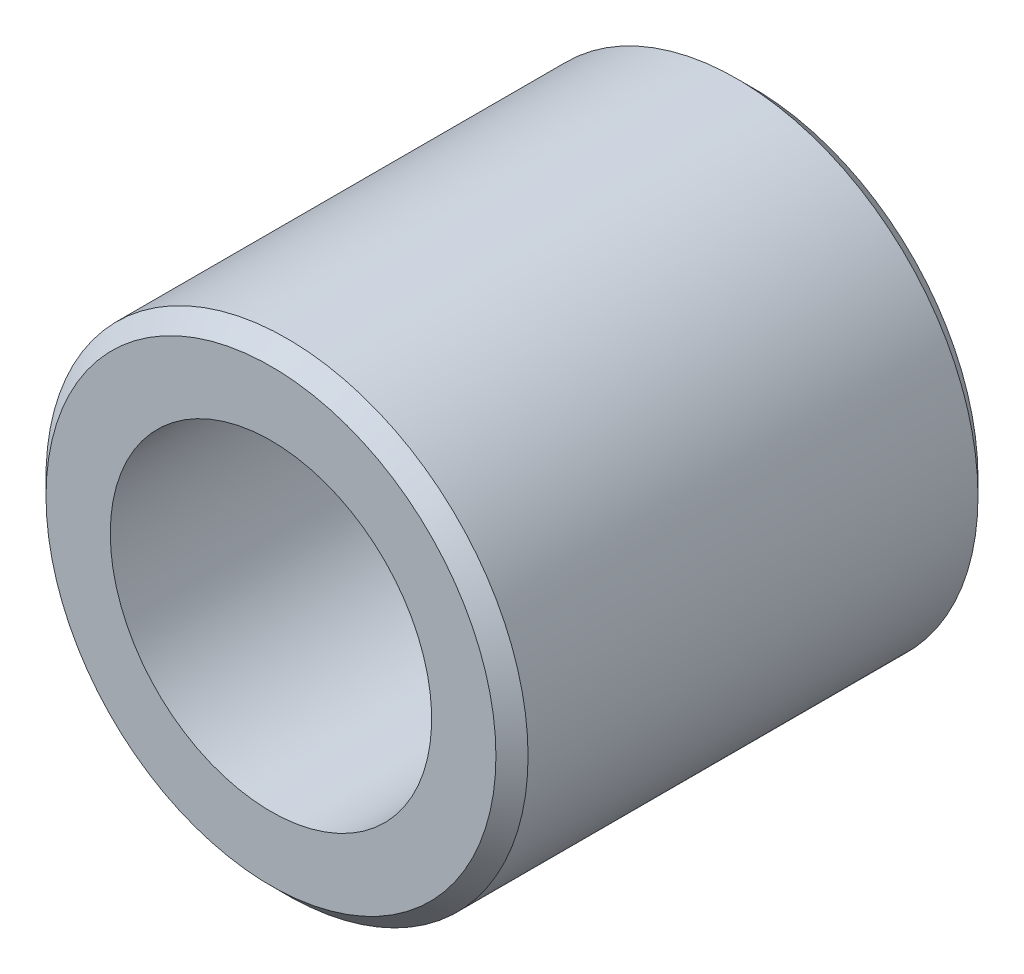
from build123d import *

# Parameters (mm, degrees)
IZIM1_R                     = 15
Y_KSEKLIK_EKSTR_ZYON1_DEPTH = 30
IZIM2_R                     = 10
KES_EKSTR_ZYON1_DEPTH       = 31
PAH1_SIZE                   = 1


with BuildPart() as part:
    # Çizim1 → Yükseklik-Ekstrüzyon1 (new body)
    with BuildSketch(Plane.XY):
        Circle(IZIM1_R)
    extrude(amount=Y_KSEKLIK_EKSTR_ZYON1_DEPTH)

    # Çizim2 → Kes-Ekstrüzyon1 (cut, through all)
    with BuildSketch(Plane(origin=(0, 0, 0), x_dir=(-1, 0, 0), z_dir=(0, 0, -1))):
        Circle(IZIM2_R)
    extrude(amount=-KES_EKSTR_ZYON1_DEPTH, mode=Mode.SUBTRACT)

    # Pah1
    pah1_edges = [part.edges().sort_by_distance(p)[0] for p in [
        (-15, 0, 0),
        (-15, 0, 30),
    ]]
    chamfer(pah1_edges, length=PAH1_SIZE)


solid = part.part
